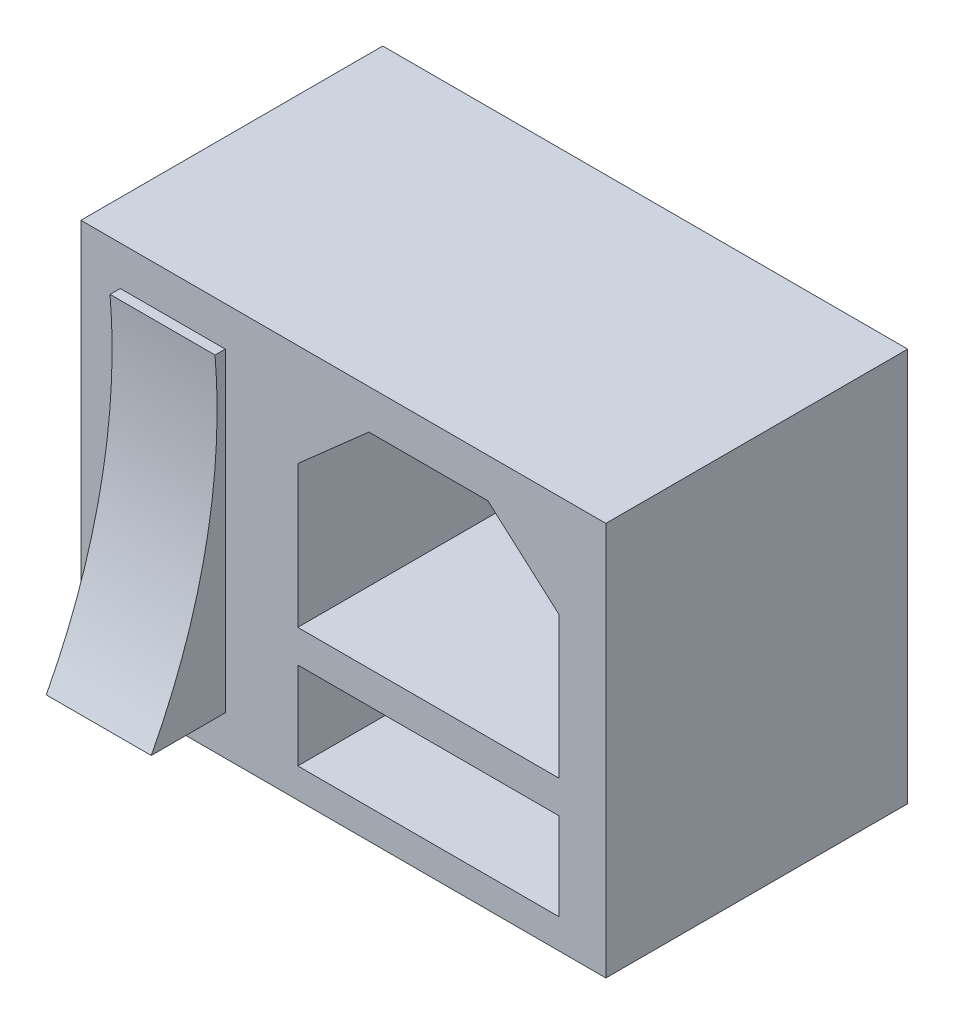
from build123d import *

# Parameters (mm, degrees)
SKETCH1_W           = 40
SKETCH1_H           = 30
BOSS_EXTRUDE1_DEPTH = 23
SKETCH2_W           = 19.900467999
SKETCH2_H           = 6.66107141
CUT_EXTRUDE1_DEPTH  = 19
SKETCH3_R           = 2
CUT_EXTRUDE2_DEPTH  = 19
BOSS_EXTRUDE2_DEPTH = 8


with BuildPart() as part:
    # Sketch1 → Boss-Extrude1 (new body)
    with BuildSketch(Plane.XY):
        Rectangle(SKETCH1_W, SKETCH1_H)
    extrude(amount=BOSS_EXTRUDE1_DEPTH)

    # Sketch2 → Cut-Extrude1 (cut)
    with BuildSketch(Plane.XY.offset(23)):
        Polygon((-3.475341605, 7.20854355), (-3.475341605, -3.599460948), (16.425126394, -3.599460948), (16.425126394, 7.20854355), (11.005248415, 11.99820316), (1.944536374, 11.99820316), align=None)
        with Locations((6.474892394, -9.412383513)):
            Rectangle(SKETCH2_W, SKETCH2_H)
    extrude(amount=-CUT_EXTRUDE1_DEPTH, mode=Mode.SUBTRACT)

    # Sketch3 → Cut-Extrude2 (cut)
    with BuildSketch(Plane(origin=(0, -12.742919218, 0), x_dir=(1, 0, 0), z_dir=(0, 1, 0))):
        with Locations((6.578325181, -13)):
            Circle(SKETCH3_R)
    extrude(amount=-CUT_EXTRUDE2_DEPTH, mode=Mode.SUBTRACT)

    # Sketch4 → Boss-Extrude2 (add)
    with BuildSketch(Plane.ZY.offset(17)):
        with BuildLine():
            Line((23, 12), (23.778195764, 12))
            ThreePointArc((23.778195764, 12), (24.486476148, -0.348459209), (28.637102986, -12))
            Line((28.637102986, -12), (23, -12))
            Line((23, -12), (23, 12))
        make_face()
    extrude(amount=-BOSS_EXTRUDE2_DEPTH)


solid = part.part
